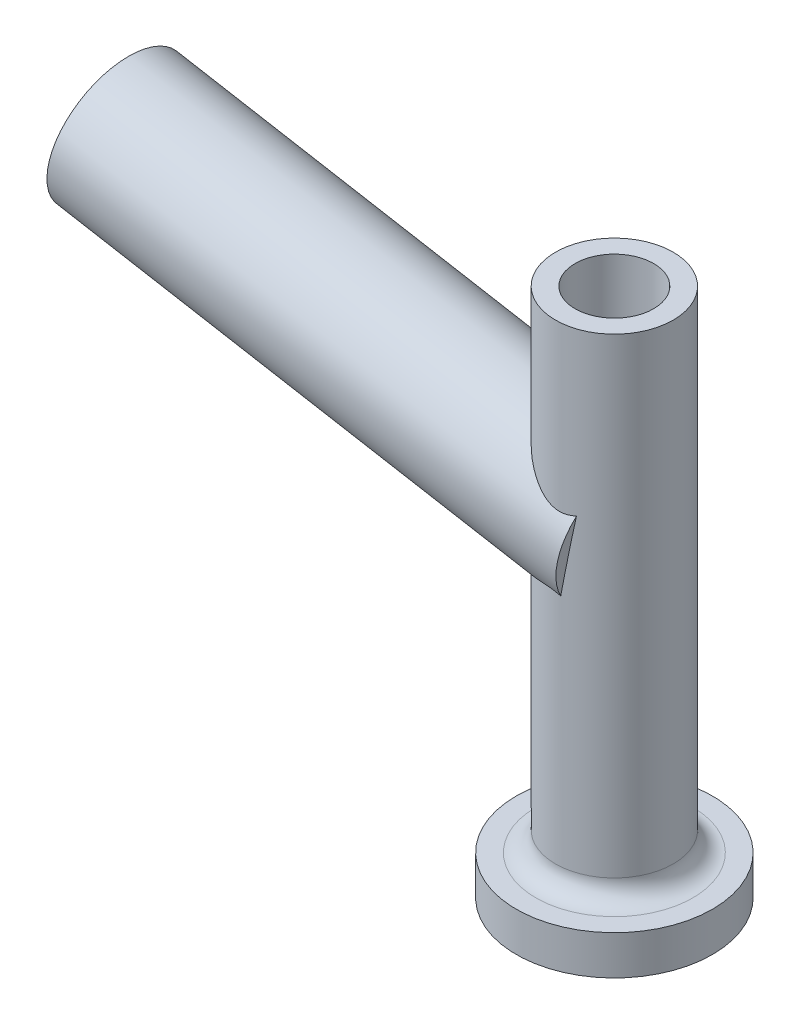
from build123d import *

# Parameters (mm, degrees)
SKETCH11_R          = 35
BOSS_EXTRUDE2_DEPTH = 263.365760626
FILLET2_R           = 10
SKETCH15_R          = 20
CUT_EXTRUDE1_DEPTH  = 378.961489357


with BuildPart() as part:
    # Sketch14 → Revolve3 (revolve)
    with BuildSketch(Plane.XY):
        Polygon((30, -115), (30, 135), (20, 135), (20, -135), (50, -135), (50, -115), align=None)
    revolve(axis=Axis((0, -135, 0), (0, 1, 0)))

    # Sketch11 → Boss-Extrude2 (add)
    with BuildSketch(Plane(origin=(0.069700253, 0.395289776, -0.070775492), x_dir=(-0.03015368960704645, -0.17101007166283763, -0.9848077530122075), z_dir=(0.984807753012208, -0.17364817766693072, 0))):
        with Locations((-5.721541908, 32.04089679)):
            Circle(SKETCH11_R)
    extrude(amount=-BOSS_EXTRUDE2_DEPTH)

    # Fillet2
    fillet2_edges = [part.edges().sort_by_distance(p)[0] for p in [
        (-30, -115, 0),
    ]]
    fillet(fillet2_edges, radius=FILLET2_R)

    # Sketch15 → Cut-Extrude1 (cut, through all)
    with BuildSketch(Plane(origin=(0, 135, 0), x_dir=(1, 0, 0), z_dir=(0, 1, 0))):
        Circle(SKETCH15_R)
    extrude(amount=-CUT_EXTRUDE1_DEPTH, mode=Mode.SUBTRACT)


solid = part.part
